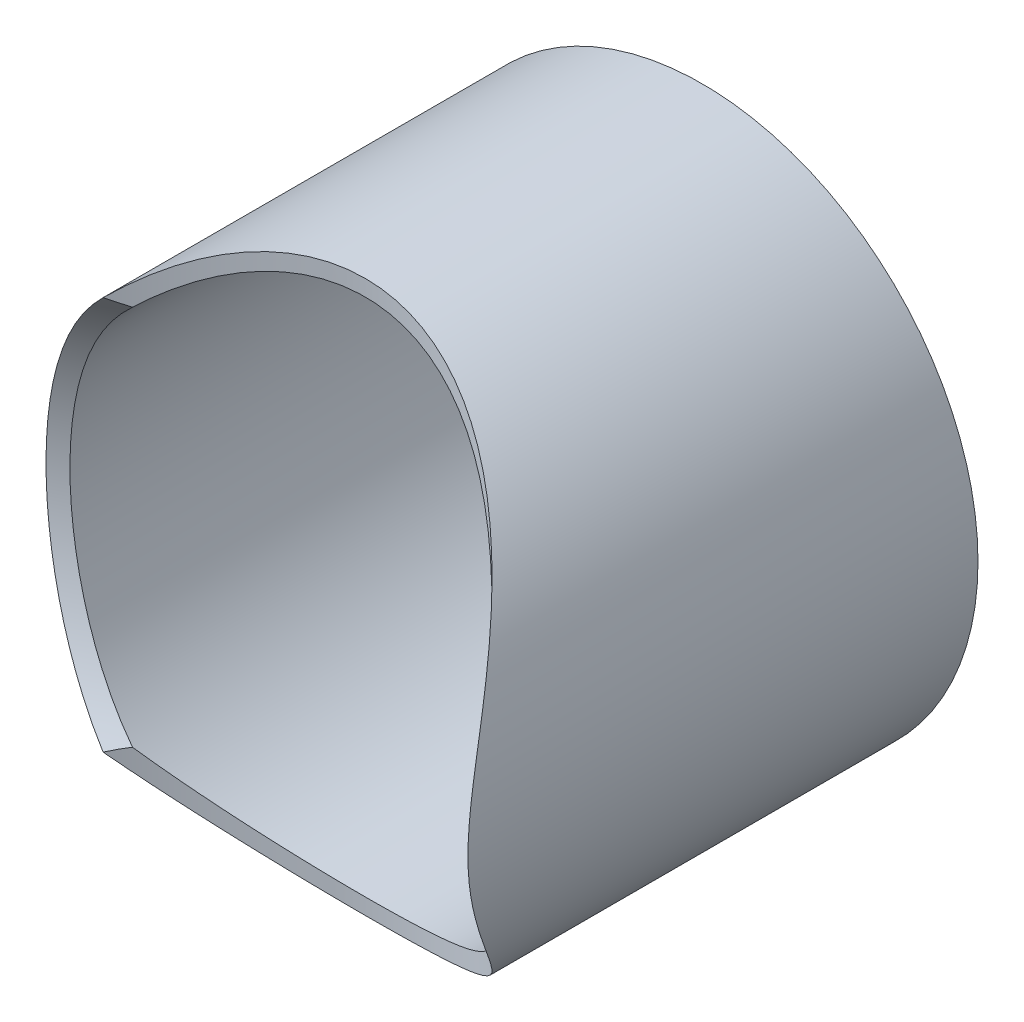
from build123d import *

# Parameters (mm, degrees)
SKETCH1_R           = 17.15
SKETCH1_R_2         = 16.15
BOSS_EXTRUDE1_DEPTH = 40
SKETCH2_R           = 22.225
CUT_EXTRUDE1_DEPTH  = 352.453482
SKETCH3_R           = 19.05
CUT_EXTRUDE2_DEPTH  = 52.6500001


with BuildPart() as part:
    # Sketch1 → Boss-Extrude1 (new body)
    with BuildSketch(Plane.XY):
        with Locations((316.783091477, 0)):
            Circle(SKETCH1_R)
        with Locations((316.783091477, 0)):
            Circle(SKETCH1_R_2, mode=Mode.SUBTRACT)
    extrude(amount=-BOSS_EXTRUDE1_DEPTH)

    # Sketch2 → Cut-Extrude1 (cut)
    with BuildSketch(Plane(origin=(-60.87597301, 0, 29.691195898), x_dir=(-0.438371147, 0, -0.898794046), z_dir=(0.898794046, 0, -0.438371147))):
        with Locations((-138.868567094, 0)):
            Circle(SKETCH2_R)
    extrude(amount=CUT_EXTRUDE1_DEPTH, mode=Mode.SUBTRACT)

    # Sketch3 → Cut-Extrude2 (cut, through all)
    with BuildSketch(Plane.XZ.offset(34.5)):
        with Locations((316.783091477, 0)):
            Circle(SKETCH3_R)
    extrude(amount=-CUT_EXTRUDE2_DEPTH, mode=Mode.SUBTRACT)


solid = part.part
